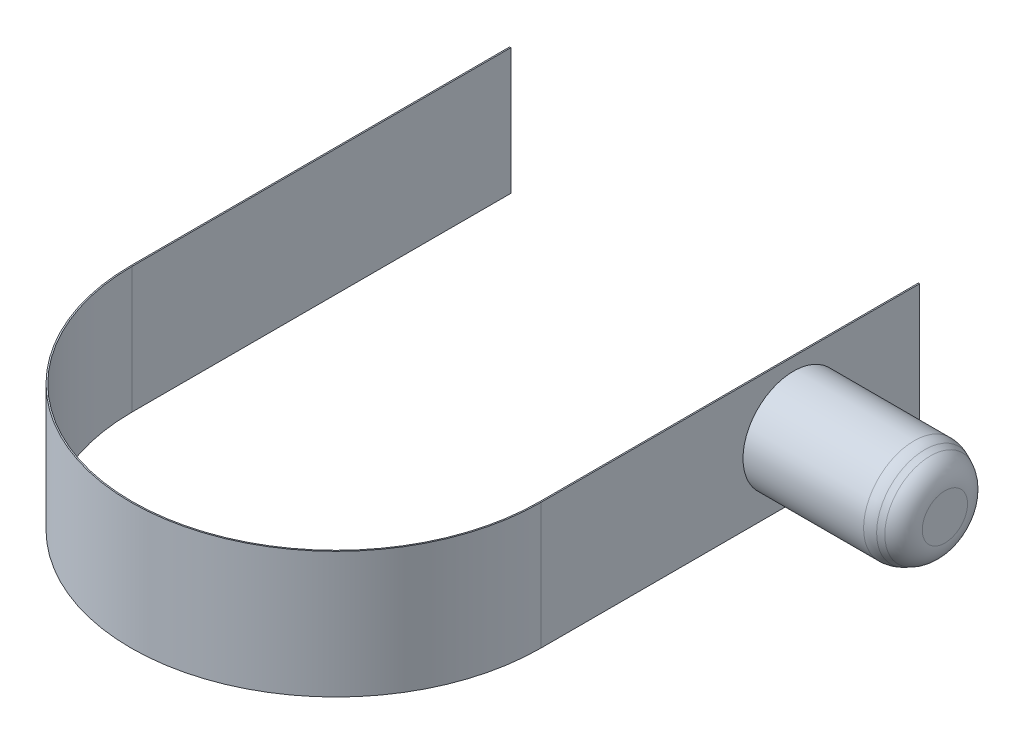
from build123d import *

# Parameters (mm, degrees)
EXTRUDE_THIN1_DEPTH = 5
SKETCH5_W           = 26.389754353
SKETCH5_H           = 10
BOSS_EXTRUDE1_DEPTH = 0.1
SKETCH6_R           = 4
BOSS_EXTRUDE2_DEPTH = 12
CHAMFER1_SIZE       = 2
CHAMFER1_SIZE2      = 0.932615316
FILLET1_R           = 2


with BuildPart() as part:
    # Sketch3 → Extrude-Thin1 (new body, symmetric)
    with BuildSketch(Plane(origin=(0, 0, 0), x_dir=(1, 0, 0), z_dir=(0, 1, 0))):
        with BuildLine():
            Line((16.248076809, 30), (16.248076809, 0))
            ThreePointArc((16.248076809, 0), (0, -16.248076809), (-16.248076809, 0))
            Line((-16.248076809, 0), (-16.248076809, 30))
            Line((-16.248076809, 30), (-16.148076809, 30))
            Line((-16.148076809, 30), (-16.148076809, 0))
            ThreePointArc((-16.148076809, 0), (0, -16.148076809), (16.148076809, 0))
            Line((16.148076809, 0), (16.148076809, 30))
            Line((16.148076809, 30), (16.248076809, 30))
        make_face()
    extrude(amount=EXTRUDE_THIN1_DEPTH, both=True)

    # Sketch5 → Boss-Extrude1 (add)
    with BuildSketch(Plane.ZY.offset(16.248076809)):
        with Locations((-13.194877177, 0)):
            Rectangle(SKETCH5_W, SKETCH5_H)
    extrude(amount=-BOSS_EXTRUDE1_DEPTH)

    # Sketch6 → Boss-Extrude2 (add)
    with BuildSketch(Plane(origin=(16.248076809, 0, 0), x_dir=(0, 0, -1), z_dir=(1, 0, 0))):
        with Locations((20, 0)):
            Circle(SKETCH6_R)
    extrude(amount=BOSS_EXTRUDE2_DEPTH)

    # Chamfer1
    chamfer1_edges = [part.edges().sort_by_distance(p)[0] for p in [
        (28.248076809, 0, -16),
    ]]
    chamfer1_side = [part.faces().sort_by_distance(p)[0] for p in [
        (22.248076809, 0, -16),
    ]]
    chamfer(chamfer1_edges, length=CHAMFER1_SIZE, length2=CHAMFER1_SIZE2, reference=chamfer1_side[0])

    # Fillet1
    fillet1_edges = [part.edges().sort_by_distance(p)[0] for p in [
        (28.248076809, 0, -16.932615316),
        (26.248076809, 0, -16),
    ]]
    fillet(fillet1_edges, radius=FILLET1_R)


solid = part.part
